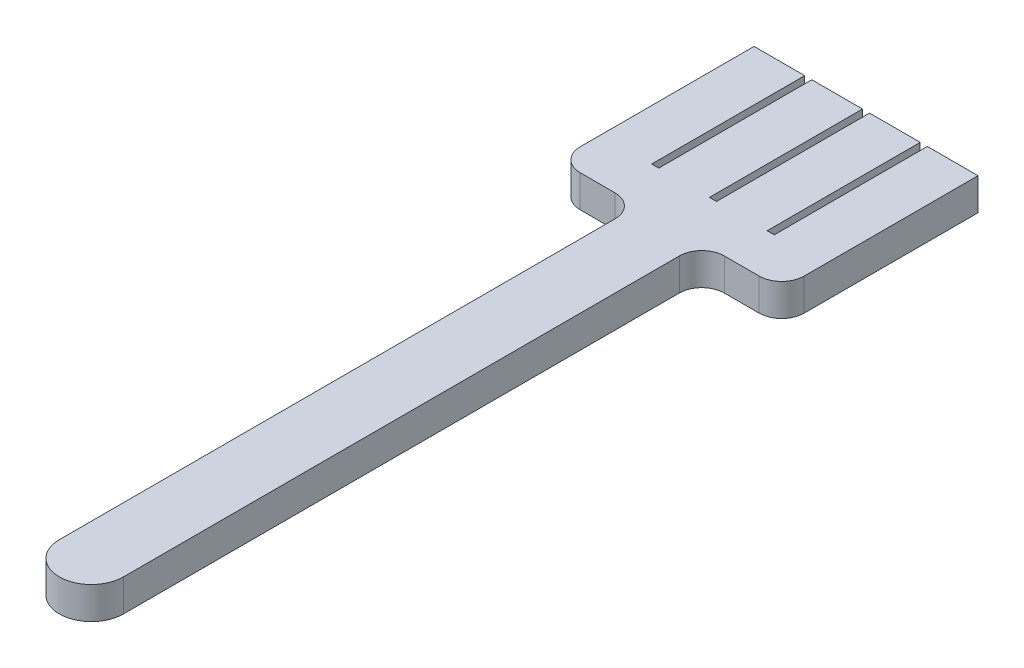
from build123d import *

# Parameters (mm, degrees)
BOSS_EXTRUDE1_DEPTH = 10
FILLET2_R           = 7


with BuildPart() as part:
    # Sketch1 → Boss-Extrude1 (new body)
    with BuildSketch(Plane(origin=(0, 0, 0), x_dir=(1, 0, 0), z_dir=(0, 1, 0))):
        with BuildLine():
            Line((0, 0), (0, 180))
            Line((0, 180), (-24.84953376, 180))
            Line((-24.84953376, 180), (-24.84953376, 241.105739003))
            Line((-24.84953376, 241.105739003), (-9.081721857, 241.105739003))
            Line((-9.081721857, 241.105739003), (-9.081721857, 193.469393381))
            Line((-9.081721857, 193.469393381), (-6.872448555, 193.469393381))
            Line((-6.872448555, 193.469393381), (-6.872448555, 241.105739003))
            Line((-6.872448555, 241.105739003), (8.895363349, 241.105739003))
            Line((8.895363349, 241.105739003), (8.895363349, 193.469393381))
            Line((8.895363349, 193.469393381), (11.104636651, 193.469393381))
            Line((11.104636651, 193.469393381), (11.104636651, 241.105739003))
            Line((11.104636651, 241.105739003), (26.872448555, 241.105739003))
            Line((26.872448555, 241.105739003), (26.872448555, 193.469393381))
            Line((26.872448555, 193.469393381), (29.081721857, 193.469393381))
            Line((29.081721857, 193.469393381), (29.081721857, 241.105739003))
            Line((29.081721857, 241.105739003), (44.84953376, 241.105739003))
            Line((44.84953376, 241.105739003), (44.84953376, 180))
            Line((44.84953376, 180), (20, 180))
            Line((20, 180), (20, 0))
            ThreePointArc((20, 0), (10, -10), (0, 0))
        make_face()
    extrude(amount=BOSS_EXTRUDE1_DEPTH)

    # Fillet2
    fillet2_edges = [part.edges().sort_by_distance(p)[0] for p in [
        (0, 5, -180),
        (-24.84953376, 5, -180),
        (44.84953376, 5, -180),
        (20, 5, -180),
    ]]
    fillet(fillet2_edges, radius=FILLET2_R)


solid = part.part
